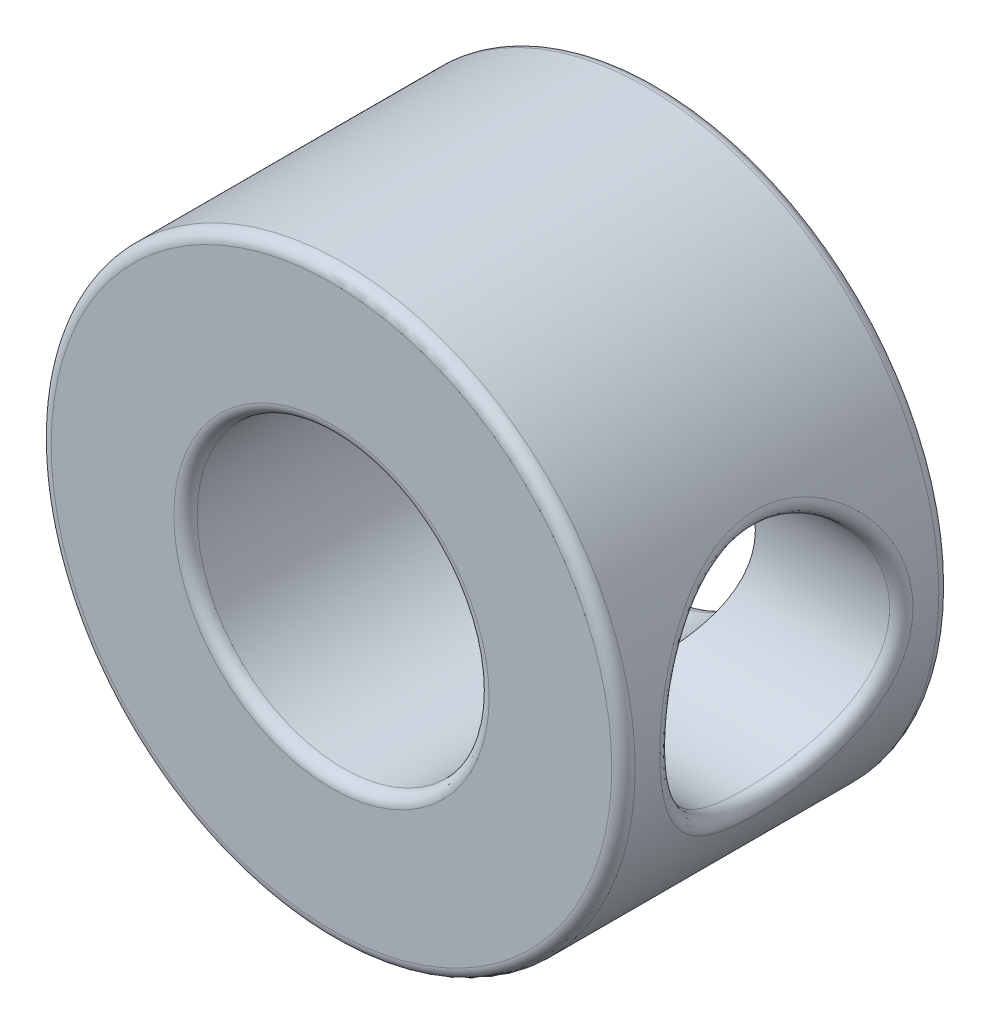
from build123d import *

# Parameters (mm, degrees)
SKETCH2_R           = 6.35
BOSS_EXTRUDE1_DEPTH = 7.112
SKETCH3_R           = 3.175
CUT_EXTRUDE1_DEPTH  = 19.05
SKETCH4_R           = 2.499999953
CUT_EXTRUDE2_DEPTH  = 19.05
FILLET1_R           = 0.254


with BuildPart() as part:
    # Sketch2 → Boss-Extrude1 (new body)
    with BuildSketch(Plane.XY):
        Circle(SKETCH2_R)
    extrude(amount=BOSS_EXTRUDE1_DEPTH)

    # Sketch3 → Cut-Extrude1 (cut)
    with BuildSketch(Plane.XY.offset(7.112)):
        Circle(SKETCH3_R)
    extrude(amount=-CUT_EXTRUDE1_DEPTH, mode=Mode.SUBTRACT)

    # Sketch4 → Cut-Extrude2 (cut)
    with BuildSketch(Plane(origin=(0, 0, 0), x_dir=(0, 0, -1), z_dir=(1, 0, 0))):
        with Locations((-3.5687, 0)):
            Circle(SKETCH4_R)
    extrude(amount=CUT_EXTRUDE2_DEPTH, mode=Mode.SUBTRACT)

    # Fillet1
    fillet1_edges = [part.edges().sort_by_distance(p)[0] for p in [
        (5.837165428, 2.499999953, 3.5687),
        (-6.35, 0, 0),
        (-6.35, 0, 7.112),
        (-3.175, 0, 0),
        (-3.175, 0, 7.112),
    ]]
    fillet(fillet1_edges, radius=FILLET1_R)


solid = part.part
